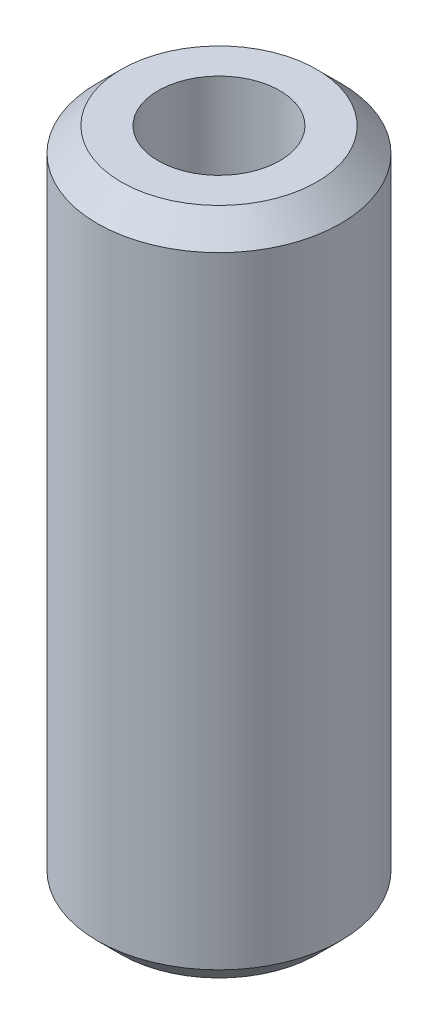
from build123d import *

# Parameters (mm, degrees)
SKETCH1_R           = 12.7
SKETCH1_R_2         = 6.35
BOSS_EXTRUDE1_DEPTH = 34.925
CHAMFER1_SIZE       = 2.5


with BuildPart() as part:
    # Sketch1 → Boss-Extrude1 (new body, symmetric)
    with BuildSketch(Plane(origin=(0, 0, 0), x_dir=(1, 0, 0), z_dir=(0, 1, 0))):
        Circle(SKETCH1_R)
        Circle(SKETCH1_R_2, mode=Mode.SUBTRACT)
    extrude(amount=BOSS_EXTRUDE1_DEPTH, both=True)

    # Chamfer1
    chamfer1_edges = [part.edges().sort_by_distance(p)[0] for p in [
        (-12.7, -34.925, 0),
        (-12.7, 34.925, 0),
    ]]
    chamfer(chamfer1_edges, length=CHAMFER1_SIZE)


solid = part.part
